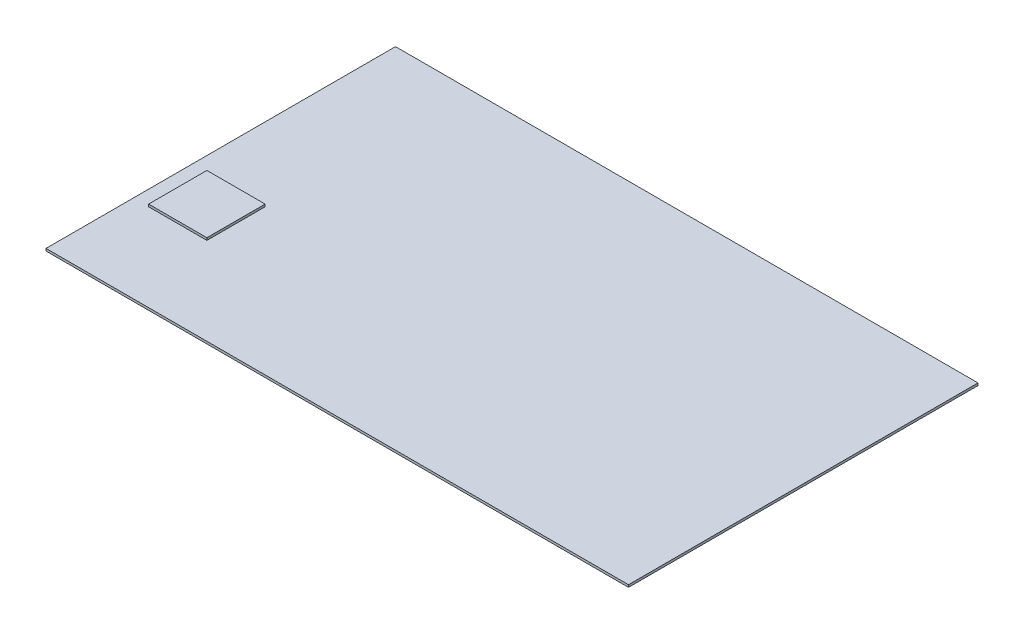
from build123d import *

# Parameters (mm, degrees)
SKETCH1_W           = 250
SKETCH1_H           = 150
BOSS_EXTRUDE1_DEPTH = 1
SKETCH2_W           = 25
SKETCH2_H           = 25
BOSS_EXTRUDE2_DEPTH = 1


with BuildPart() as part:
    # Sketch1 → Boss-Extrude1 (new body)
    with BuildSketch(Plane(origin=(0, 0, 0), x_dir=(1, 0, 0), z_dir=(0, 1, 0))):
        with Locations((87.454288838, -17.547640784)):
            Rectangle(SKETCH1_W, SKETCH1_H)
    extrude(amount=BOSS_EXTRUDE1_DEPTH)

    # Sketch2 → Boss-Extrude2 (add)
    with BuildSketch(Plane(origin=(0, 1, 0), x_dir=(1, 0, 0), z_dir=(0, 1, 0))):
        with Locations((-18.495711162, -42.547640784)):
            Rectangle(SKETCH2_W, SKETCH2_H)
    extrude(amount=BOSS_EXTRUDE2_DEPTH)


solid = part.part
